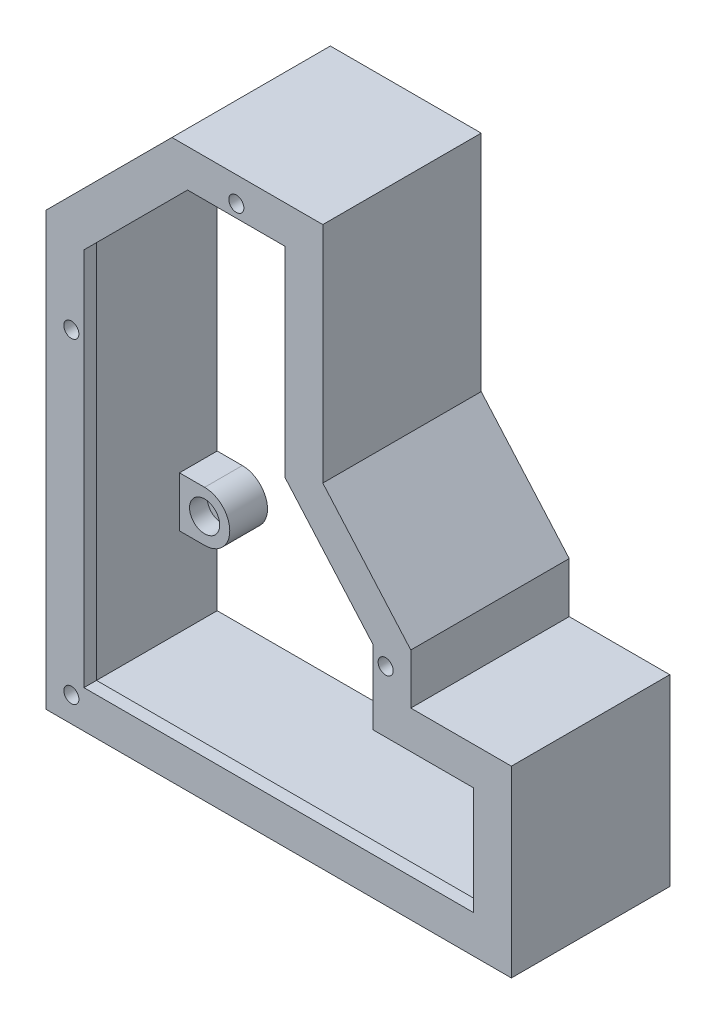
from build123d import *

# Parameters (mm, degrees)
EXTRUDE_1_DEPTH     = 63
SKETCH_2_W          = 185
SKETCH_2_H          = 5
CUT_EXTRUDE_1_DEPTH = 114
SHELL_1_T           = -5
CUT_EXTRUDE_2_DEPTH = 10
EXTRUDE_2_DEPTH     = 15
SKETCH_5_R          = 3
CUT_EXTRUDE_3_DEPTH = 35
SKETCH_6_R          = 6
CUT_EXTRUDE_4_DEPTH = 7
SKETCH_8_R          = 3
CUT_EXTRUDE_5_DEPTH = 10


with BuildPart() as part:
    # 草图1 → 凸台-拉伸1 (new body)
    with BuildSketch(Plane.XY):
        Polygon((100, -2.031815791), (60, -2.031815791), (60, 17.968184209), (25, 57.968184209), (25, 147), (-35, 147), (-85, 97), (-85, -80), (100, -80), align=None)
    extrude(amount=EXTRUDE_1_DEPTH)

    # 草图2 → 切除-拉伸1 (cut)
    with BuildSketch(Plane.XY.offset(63)):
        with Locations((7.5, -77.5)):
            Rectangle(SKETCH_2_W, SKETCH_2_H)
    extrude(amount=-CUT_EXTRUDE_1_DEPTH, mode=Mode.SUBTRACT)

    # 抽壳1
    shell_1_openings = [part.faces().sort_by_distance(p)[0] for p in [
        (18.333333333, 34.763637426, 0),
    ]]
    offset(amount=SHELL_1_T, openings=shell_1_openings, kind=Kind.INTERSECTION)

    # 草图3 → 切除-拉伸2 (cut)
    with BuildSketch(Plane(origin=(0, 0, 58), x_dir=(-1, 0, 0), z_dir=(0, 0, -1))):
        Polygon((-85, -60), (70, -60), (70, 90.786796564), (28.786796564, 132), (-10, 132), (-10, 52.332157467), (-45, 12.332157467), (-45, -17.031815791), (-85, -17.031815791), align=None)
    extrude(amount=-CUT_EXTRUDE_2_DEPTH, mode=Mode.SUBTRACT)

    # 草图4 → 凸台-拉伸2 (add)
    with BuildSketch(Plane(origin=(0, 0, 0), x_dir=(-1, 0, 0), z_dir=(0, 0, -1))):
        with BuildLine():
            Line((63.535533906, 111.393398282), (56.464466094, 104.32233047))
            ThreePointArc((56.464466094, 104.32233047), (42.32233047, 104.32233047), (42.32233047, 118.464466094))
            Line((42.32233047, 118.464466094), (49.393398282, 125.535533906))
            Line((49.393398282, 125.535533906), (63.535533906, 111.393398282))
        make_face()
        with BuildLine():
            Line((70, -15), (80, -15))
            Line((80, -15), (80, -35))
            Line((80, -35), (70, -35))
            ThreePointArc((70, -35), (60, -25), (70, -15))
        make_face()
        with BuildLine():
            Line((-40, -60), (-40, -70))
            Line((-40, -70), (-60, -70))
            Line((-60, -70), (-60, -60))
            ThreePointArc((-60, -60), (-50, -50), (-40, -60))
        make_face()
        with BuildLine():
            Line((-10, 127), (-20, 127))
            Line((-20, 127), (-20, 107))
            Line((-20, 107), (-10, 107))
            ThreePointArc((-10, 107), (0, 117), (-10, 127))
        make_face()
    extrude(amount=-EXTRUDE_2_DEPTH)

    # 草图5 → 切除-拉伸3 (cut)
    with BuildSketch(Plane(origin=(0, 0, 0), x_dir=(-1, 0, 0), z_dir=(0, 0, -1))):
        with Locations((49.393398282, 111.393398282)):
            Circle(SKETCH_5_R)
        with Locations((-10, 117)):
            Circle(SKETCH_5_R)
        with Locations((70, -25)):
            Circle(SKETCH_5_R)
        with Locations((-50, -60)):
            Circle(SKETCH_5_R)
    extrude(amount=-CUT_EXTRUDE_3_DEPTH, mode=Mode.SUBTRACT)

    # 草图6 → 切除-拉伸4 (cut)
    with BuildSketch(Plane.XY.offset(15)):
        with Locations((10, 117)):
            Circle(SKETCH_6_R)
        with Locations((-49.393398282, 111.393398282)):
            Circle(SKETCH_6_R)
        with Locations((50, -60)):
            Circle(SKETCH_6_R)
        with Locations((-70, -25)):
            Circle(SKETCH_6_R)
    extrude(amount=-CUT_EXTRUDE_4_DEPTH, mode=Mode.SUBTRACT)

    # 草图8 → 切除-拉伸5 (cut)
    with BuildSketch(Plane.XY.offset(63)):
        with Locations((-9.393398282, 137)):
            Circle(SKETCH_8_R)
        with Locations((-75, -65)):
            Circle(SKETCH_8_R)
        with Locations((-75, 60.786796564)):
            Circle(SKETCH_8_R)
        with Locations((50, 7.332157467)):
            Circle(SKETCH_8_R)
    extrude(amount=-CUT_EXTRUDE_5_DEPTH, mode=Mode.SUBTRACT)


solid = part.part
